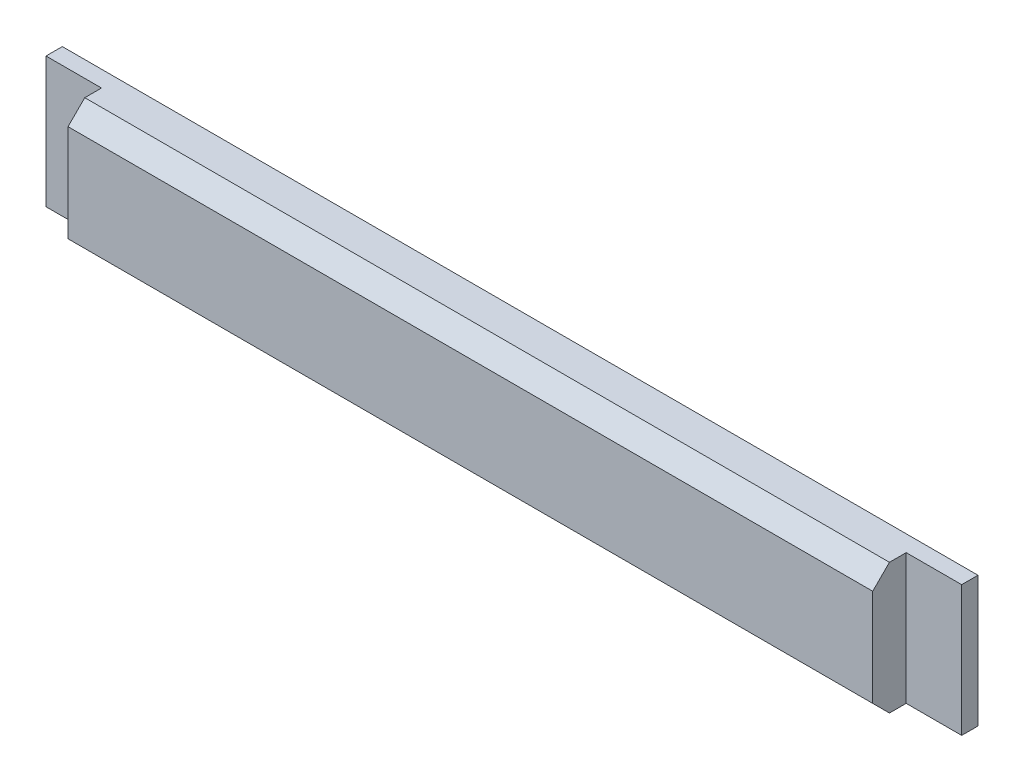
from build123d import *

# Parameters (mm, degrees)
ESQUISSE1_W             = 280.5
ESQUISSE1_H             = 40
BOSS_EXTRU_1_DEPTH      = 5
ESQUISSE2_W             = 246.5
ESQUISSE2_H             = 40
BOSS_EXTRU_2_DEPTH      = 10.25
ENL_V_MAT_EXTRU_1_REACH = 265.5


with BuildPart() as part:
    # Esquisse1 → Boss.-Extru.1 (new body)
    with BuildSketch(Plane.XY):
        with Locations((2.164847162, 117.813864629)):
            Rectangle(ESQUISSE1_W, ESQUISSE1_H)
    extrude(amount=BOSS_EXTRU_1_DEPTH)

    # Esquisse2 → Boss.-Extru.2 (add)
    with BuildSketch(Plane.XY.offset(5)):
        with Locations((2.164847162, 117.813864629)):
            Rectangle(ESQUISSE2_W, ESQUISSE2_H)
    extrude(amount=BOSS_EXTRU_2_DEPTH)

    # Esquisse3 → Enlèv. mat.-Extru.1 (cut, up to next)
    with BuildSketch(Plane.ZY.offset(121.085152838), mode=Mode.PRIVATE) as enl_v_mat_extru_1_sk1:
        Polygon((10.125, 137.813864629), (15.25, 137.813864629), (15.25, 132.688864629), align=None)
    enl_v_mat_extru_1_tool1 = extrude(enl_v_mat_extru_1_sk1.sketch, amount=-ENL_V_MAT_EXTRU_1_REACH, mode=Mode.PRIVATE) & part.part
    add(enl_v_mat_extru_1_tool1.solids().sort_by_distance((-121.085153, 136.105531, 13.541667))[0], mode=Mode.SUBTRACT)
    # Esquisse3 → Enlèv. mat.-Extru.1 (cut, up to next)
    with BuildSketch(Plane.ZY.offset(121.085152838), mode=Mode.PRIVATE) as enl_v_mat_extru_1_sk2:
        Polygon((15.25, 97.813864629), (15.25, 102.938864629), (10.125, 97.813864629), align=None)
    enl_v_mat_extru_1_tool2 = extrude(enl_v_mat_extru_1_sk2.sketch, amount=-ENL_V_MAT_EXTRU_1_REACH, mode=Mode.PRIVATE) & part.part
    add(enl_v_mat_extru_1_tool2.solids().sort_by_distance((-121.085153, 99.522198, 13.541667))[0], mode=Mode.SUBTRACT)


solid = part.part
